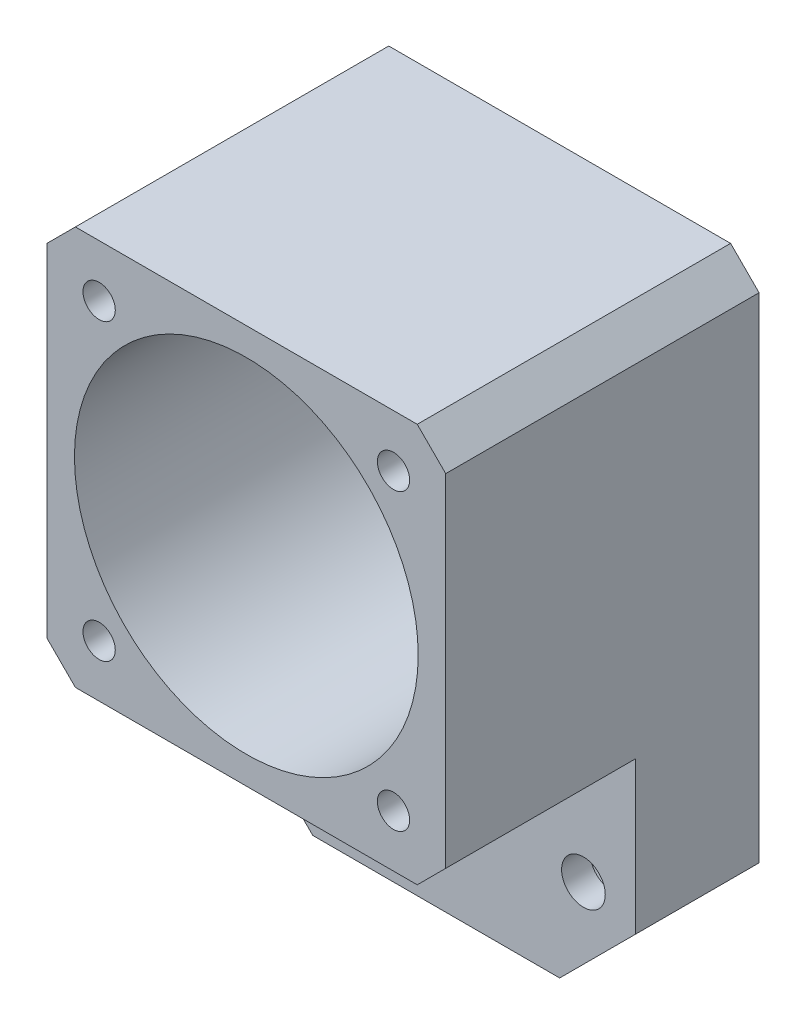
from build123d import *

# Parameters (mm, degrees)
SKIZZE1_W                       = 42
SKIZZE1_H                       = 63
SKIZZE1_R                       = 18.1
SKIZZE1_R_2                     = 1.7
SKIZZE1_R_3                     = 2.3
AUFSATZ_LINEAR_AUSTRAGEN1_DEPTH = 13
SKIZZE2_W                       = 42
SKIZZE2_H                       = 42
SKIZZE2_R                       = 18.1
SKIZZE2_R_2                     = 1.7
AUFSATZ_LINEAR_AUSTRAGEN2_DEPTH = 20
SKIZZE4_R                       = 4
SCHNITT_LINEAR_AUSTRAGEN1_DEPTH = 10
SKIZZE5_R                       = 2.9
SCHNITT_LINEAR_AUSTRAGEN2_DEPTH = 30
FASE1_SIZE                      = 3
FASE2_SIZE                      = 8


with BuildPart() as part:
    # Skizze1 → Aufsatz-Linear austragen1 (new body)
    with BuildSketch(Plane.XY):
        with Locations((0, -10.5)):
            Rectangle(SKIZZE1_W, SKIZZE1_H)
        Circle(SKIZZE1_R, mode=Mode.SUBTRACT)
        with Locations((-15.5, 15.5)):
            Circle(SKIZZE1_R_2, mode=Mode.SUBTRACT)
        with Locations((15.5, 15.5)):
            Circle(SKIZZE1_R_2, mode=Mode.SUBTRACT)
        with Locations((-15.5, -15.5)):
            Circle(SKIZZE1_R_2, mode=Mode.SUBTRACT)
        with Locations((15.5, -15.5)):
            Circle(SKIZZE1_R_2, mode=Mode.SUBTRACT)
        with Locations((-15.5, -32)):
            Circle(SKIZZE1_R_3, mode=Mode.SUBTRACT)
        with Locations((15.5, -32)):
            Circle(SKIZZE1_R_3, mode=Mode.SUBTRACT)
    extrude(amount=AUFSATZ_LINEAR_AUSTRAGEN1_DEPTH)

    # Skizze2 → Aufsatz-Linear austragen2 (add)
    with BuildSketch(Plane.XY.offset(13)):
        Rectangle(SKIZZE2_W, SKIZZE2_H)
        Circle(SKIZZE2_R, mode=Mode.SUBTRACT)
        with Locations((15.5, 15.5)):
            Circle(SKIZZE2_R_2, mode=Mode.SUBTRACT)
        with Locations((15.5, -15.5)):
            Circle(SKIZZE2_R_2, mode=Mode.SUBTRACT)
        with Locations((-15.5, -15.5)):
            Circle(SKIZZE2_R_2, mode=Mode.SUBTRACT)
        with Locations((-15.5, 15.5)):
            Circle(SKIZZE2_R_2, mode=Mode.SUBTRACT)
    extrude(amount=AUFSATZ_LINEAR_AUSTRAGEN2_DEPTH)

    # Skizze4 → Schnitt-Linear austragen1 (cut)
    with BuildSketch(Plane.XY):
        with Locations((-15.5, -32)):
            Circle(SKIZZE4_R)
        with Locations((15.5, -32)):
            Circle(SKIZZE4_R)
    extrude(amount=SCHNITT_LINEAR_AUSTRAGEN1_DEPTH, mode=Mode.SUBTRACT)

    # Skizze5 → Schnitt-Linear austragen2 (cut)
    with BuildSketch(Plane.XY):
        with Locations((-15.5, 15.5)):
            Circle(SKIZZE5_R)
        with Locations((15.5, 15.5)):
            Circle(SKIZZE5_R)
        with Locations((-15.5, -15.5)):
            Circle(SKIZZE5_R)
        with Locations((15.5, -15.5)):
            Circle(SKIZZE5_R)
    extrude(amount=SCHNITT_LINEAR_AUSTRAGEN2_DEPTH, mode=Mode.SUBTRACT)

    # Fase1
    fase1_edges = [part.edges().sort_by_distance(p)[0] for p in [
        (-21, -21, 23),
        (21, -21, 23),
        (-21, 21, 16.5),
        (21, 21, 16.5),
    ]]
    chamfer(fase1_edges, length=FASE1_SIZE)

    # Fase2
    fase2_edges = [part.edges().sort_by_distance(p)[0] for p in [
        (21, -42, 6.5),
        (-21, -42, 6.5),
    ]]
    chamfer(fase2_edges, length=FASE2_SIZE)


solid = part.part
